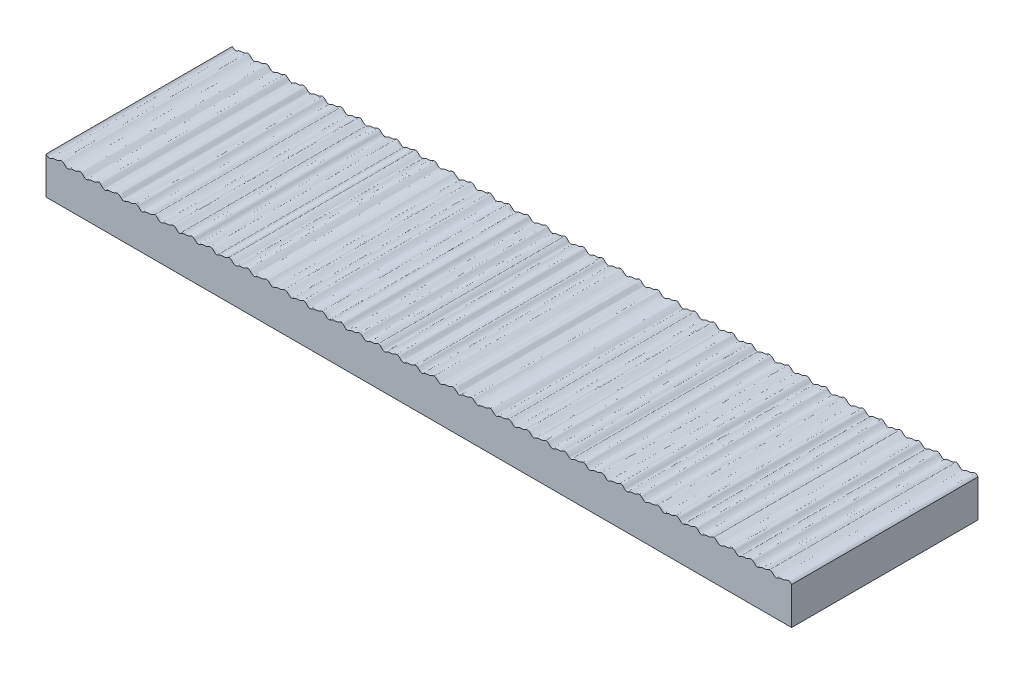
from build123d import *

# Parameters (mm, degrees)
AUFSATZ_LINEAR_AUSTRAGEN1_DEPTH = 50


with BuildPart() as part:
    # Skizze1 → Aufsatz-Linear austragen1 (new body)
    with BuildSketch(Plane.XY):
        with BuildLine():
            Line((0, 10), (0, 0))
            Line((0, 0), (200, 0))
            Line((200, 0), (200, 10))
            add(Edge.make_bspline(
                [(0, 10), (0.038871089, 9.9624255), (0.11702428, 9.886873009), (0.276737044, 9.737095424), (0.495618179, 9.574292073), (0.754441657, 9.479986587), (1.049992657, 9.511261754), (1.327344431, 9.647732145), (1.60121182, 9.808766789), (1.902075358, 9.947101731), (2.237499296, 10.009048627), (2.586757818, 9.993970597), (2.946471246, 10.009722426), (3.263298936, 10.120845427), (3.531006903, 10.268992249), (3.776360671, 10.406692069), (4.017368484, 10.500855503), (4.293691085, 10.512062256), (4.564534381, 10.393279584), (4.800469273, 10.195913237), (5.028254164, 9.971117802), (5.268757369, 9.741852772), (5.552089834, 9.524071152), (5.920599081, 9.460805432), (6.266877461, 9.61234611), (6.570328253, 9.792390203), (6.891296463, 9.946288536), (7.250351856, 10.011452379), (7.62394339, 9.990965887), (8.008625251, 10.018030827), (8.376673484, 10.174422263), (8.690787962, 10.36507936), (9.018441303, 10.517317828), (9.363236477, 10.501706612), (9.64337149, 10.3346189), (9.880145513, 10.11915348), (10.109095252, 9.891391142), (10.344924431, 9.675136757), (10.622007039, 9.503571421), (10.968628303, 9.478594675), (11.302531496, 9.630175237), (11.62068572, 9.824828569), (11.996749128, 9.984609573), (12.393610743, 10.008851228), (12.783268099, 9.987314285), (13.161026782, 10.070833664), (13.49661328, 10.245155578), (13.802756534, 10.429635366), (14.142662835, 10.536834855), (14.472635266, 10.452177992), (14.729423203, 10.260314552), (14.958198319, 10.041887758), (15.18510968, 9.818067104), (15.429495011, 9.60953776), (15.730640788, 9.472549737), (16.084248747, 9.515630957), (16.410046579, 9.696899556), (16.74774908, 9.893538576), (17.155927752, 10.014076689), (17.553067713, 9.993440973), (17.927068171, 10.006356508), (18.261848119, 10.119990196), (18.549112573, 10.278129114), (18.842465296, 10.446718051), (19.195620226, 10.546061299), (19.539019392, 10.419204885), (19.802164344, 10.192388079), (20.037064537, 9.9635673), (20.262328894, 9.746611116), (20.511601262, 9.557962321), (20.808247177, 9.471565216), (21.102847658, 9.534306739), (21.359291502, 9.667253571), (21.617045832, 9.816252525), (21.900679029, 9.945421938), (22.219126239, 10.006405946), (22.553791581, 9.996802936), (22.883121715, 10.003332903), (23.195663169, 10.091180614), (23.478068363, 10.236757212), (23.745304841, 10.393157976), (24.034272651, 10.514248601), (24.344051381, 10.503743403), (24.611045863, 10.357227987), (24.831726174, 10.165158584), (25.071246058, 9.930454513), (25.336079093, 9.673184544), (25.687032096, 9.449935604), (26.09873171, 9.521085126), (26.412296768, 9.699660856), (26.697060041, 9.859708273), (27.017604872, 9.980900347), (27.370952722, 10.00948623), (27.73813766, 9.987043257), (28.113616402, 10.053110139), (28.476265058, 10.228020595), (28.822248672, 10.452289625), (29.242208205, 10.560483904), (29.607605302, 10.367351586), (29.868946165, 10.129645547), (30.098851256, 9.901406058), (30.344722201, 9.67480196), (30.653334501, 9.480061877), (31.034864297, 9.490722074), (31.371828404, 9.675531968), (31.694469979, 9.861705889), (32.052756763, 9.993522458), (32.427494335, 10.005230593), (32.79942052, 9.990399164), (33.162357039, 10.072520288), (33.489242391, 10.241268416), (33.789859342, 10.421315157), (34.123520925, 10.535314959), (34.455474815, 10.461927375), (34.716154449, 10.272071242), (34.945125081, 10.054865901), (35.170268898, 9.832357357), (35.41192242, 9.622668881), (35.709941595, 9.47564196), (36.069404412, 9.508172221), (36.402677895, 9.69209825), (36.74529488, 9.893335316), (37.161842288, 10.015992572), (37.568598234, 9.991592755), (37.955025353, 10.009972842), (38.300756727, 10.13785313), (38.598560837, 10.307306898), (38.897179111, 10.473484133), (39.240435869, 10.534659041), (39.553847991, 10.402637659), (39.799429176, 10.195797026), (40.024293661, 9.975812646), (40.247927092, 9.760295346), (40.501491338, 9.562089987), (40.822393068, 9.462419812), (41.162490636, 9.553918035), (41.468411845, 9.732832958), (41.789407641, 9.908438311), (42.155505817, 10.007146527), (42.522720105, 9.997674758), (42.87987885, 10.000158701), (43.215424704, 10.097791717), (43.513844145, 10.257025062), (43.810232277, 10.430748729), (44.162975656, 10.546582186), (44.514544643, 10.435915535), (44.782741381, 10.210600813), (45.019571636, 9.981086348), (45.246289938, 9.760843927), (45.492142256, 9.569516453), (45.781276704, 9.474595016), (46.069307679, 9.522889165), (46.31887487, 9.64415856), (46.570713621, 9.790224661), (46.84844162, 9.926965953), (47.167688784, 10.003938775), (47.511582883, 9.99923192), (47.848444583, 9.99835257), (48.16904752, 10.079829846), (48.457283322, 10.224613704), (48.726822809, 10.383061623), (49.012528117, 10.508620252), (49.317641503, 10.509456233), (49.581857518, 10.37717567), (49.797823523, 10.197026067), (50.035322543, 9.965690671), (50.299903346, 9.707044754), (50.641543404, 9.458760107), (51.064926146, 9.505764773), (51.383368004, 9.682738036), (51.663126755, 9.84187017), (51.975955667, 9.970157985), (52.323555324, 10.010736789), (52.685713944, 9.988297998), (53.057607971, 10.035309587), (53.428813779, 10.199612309), (53.776594901, 10.425464572), (54.197154945, 10.568625599), (54.581718687, 10.388929519), (54.848223606, 10.149226694), (55.078016545, 9.922032462), (55.321943024, 9.694364324), (55.623175378, 9.490880482), (56.002405395, 9.479959539), (56.34129367, 9.65706852), (56.656563727, 9.840977742), (57.00189745, 9.981202446), (57.372255225, 10.009032536), (57.745518898, 9.987925954), (58.118377788, 10.054234062), (58.460068612, 10.223431381), (58.765567319, 10.408661135), (59.099361567, 10.532676166), (59.434536852, 10.471885152), (59.698486888, 10.287688499), (59.928809329, 10.071101948), (60.155052629, 9.846824711), (60.394978938, 9.635381313), (60.686999884, 9.481867427), (61.04228334, 9.498990436), (61.373969778, 9.674230397), (61.707101879, 9.872986595), (62.109943546, 10.00888555), (62.506940662, 9.997710842), (62.880883944, 9.999128234), (63.220203258, 10.100815565), (63.511437533, 10.25583632), (63.803203019, 10.425963249), (64.149480372, 10.545348605), (64.501336123, 10.444127777), (64.771334637, 10.221327368), (65.006885445, 9.993254753), (65.232667897, 9.775058953), (65.503344076, 9.554680283), (65.884000114, 9.44446765), (66.264440302, 9.606354531), (66.599285836, 9.812789929), (66.958851734, 9.969596686), (67.326663758, 10.010651372), (67.684591605, 9.989539475), (68.029279684, 10.031457859), (68.340485369, 10.159826707), (68.619212058, 10.319691981), (68.919557198, 10.482985277), (69.288291989, 10.537529396), (69.635951814, 10.353089588), (69.916820034, 10.07827219), (70.211248112, 9.798945292), (70.557208636, 9.486943479), (71.03219531, 9.465993417), (71.409749679, 9.706530477), (71.760997535, 9.891595694), (72.123059292, 10.00464779), (72.49735312, 9.999907774), (72.871724538, 9.995683751), (73.23345952, 10.102750608), (73.55973182, 10.282752426), (73.885605603, 10.475480738), (74.281754513, 10.54325695), (74.640158788, 10.349207633), (74.920570013, 10.074748387), (75.214913249, 9.795122222), (75.562619767, 9.484025383), (76.037923533, 9.46832622), (76.414155319, 9.709414391), (76.766154636, 9.893944989), (77.128477549, 10.005294961), (77.50271681, 9.999471765), (77.877041813, 9.996336411), (78.238277054, 10.105003127), (78.564034949, 10.285368685), (78.890457041, 10.477852405), (79.287241068, 10.542166338), (79.64413884, 10.345711497), (79.924411864, 10.070894856), (80.218542228, 9.791760605), (80.568083363, 9.480447831), (81.052787835, 9.471688932), (81.439879317, 9.725777339), (81.816627646, 9.920775845), (82.218457166, 10.017581107), (82.60948912, 9.988935845), (82.983018394, 10.017250375), (83.318090471, 10.147014102), (83.611002978, 10.314791989), (83.921534998, 10.486079123), (84.300612424, 10.537004943), (84.648113491, 10.340734792), (84.927934792, 10.071317471), (85.179302018, 9.822095099), (85.425961534, 9.61382234), (85.689835983, 9.497208174), (85.940939975, 9.491229327), (86.216662754, 9.585549981), (86.499398319, 9.749704513), (86.821552296, 9.926770029), (87.224056861, 10.015641491), (87.614758768, 9.98951945), (87.988255783, 10.018117326), (88.3227197, 10.149518207), (88.615342682, 10.317380589), (88.926470703, 10.488177114), (89.306012884, 10.535769108), (89.652095606, 10.337163387), (89.931679989, 10.067656366), (90.183139187, 9.818333432), (90.430555557, 9.610593376), (90.69534953, 9.495904626), (90.946540395, 9.492267942), (91.221658753, 9.58819184), (91.504078904, 9.752531532), (91.826757901, 9.928948846), (92.229511048, 10.015762836), (92.620096149, 9.989179736), (92.993462748, 10.019359883), (93.327348026, 10.151921362), (93.61967894, 10.31999728), (93.931420131, 10.49023876), (94.311397411, 10.534482736), (94.656059509, 10.333587209), (94.935425719, 10.063995411), (95.186978616, 9.814573357), (95.435168834, 9.607383435), (95.700877131, 9.494651791), (95.952135154, 9.493353165), (96.22664781, 9.590846955), (96.508765724, 9.755358109), (96.83198012, 9.931104199), (97.234959866, 10.015867005), (97.625451507, 9.988834609), (97.998618545, 10.020677837), (98.33210944, 10.154177683), (98.623579295, 10.323092371), (98.905630551, 10.474031258), (99.203505776, 10.524062924), (99.467871637, 10.443169682), (99.67728564, 10.301575596), (99.866865705, 10.130765074), (100.051545763, 9.949035785), (100.243107511, 9.765752409), (100.458427236, 9.596599111), (100.724498075, 9.482374151), (101.026574123, 9.502763422), (101.308226445, 9.636864299), (101.581227366, 9.797482051), (101.879174409, 9.939086115), (102.212427039, 10.007846377), (102.560915196, 9.995675011), (102.919744743, 10.005103269), (103.238977354, 10.109443757), (103.509109369, 10.256108484), (103.755301599, 10.395896655), (103.99709123, 10.496047867), (104.284603735, 10.516774391), (104.575387933, 10.390319088), (104.827713203, 10.17052581), (105.080169591, 9.919983141), (105.344284202, 9.670691058), (105.683883514, 9.463546569), (106.087196847, 9.508467312), (106.426355674, 9.709779365), (106.763433, 9.89632942), (107.134711359, 10.006897611), (107.503553121, 9.998358648), (107.856905509, 9.998771567), (108.184860943, 10.086109958), (108.47245228, 10.23345417), (108.759999624, 10.401107552), (109.09619878, 10.539988081), (109.459176706, 10.471052568), (109.743064087, 10.247765267), (109.985442945, 10.014560047), (110.218379607, 9.788544084), (110.495193531, 9.557053963), (110.890608574, 9.440468697), (111.28237732, 9.61651884), (111.627570207, 9.829754481), (112.006154983, 9.984342725), (112.387720723, 10.00849239), (112.753287622, 9.988803875), (113.09676525, 10.052778373), (113.39728466, 10.191145638), (113.665473588, 10.346293141), (113.960188574, 10.496483226), (114.316405826, 10.527421546), (114.623735107, 10.352816412), (114.867593351, 10.130525672), (115.087912047, 9.91272187), (115.299587619, 9.716680451), (115.565135971, 9.525894316), (115.929742065, 9.457619466), (116.305533345, 9.629828254), (116.665263622, 9.853031112), (117.090831447, 10.012418605), (117.540423452, 9.994409356), (117.948515973, 10.003127498), (118.291213395, 10.135577545), (118.568879091, 10.290450861), (118.810694122, 10.424050485), (119.117793054, 10.533089356), (119.489450969, 10.465839859), (119.768010227, 10.22410267), (120.014901025, 9.985352092), (120.232483911, 9.776361831), (120.431693514, 9.617328912), (120.717647158, 9.473498724), (121.107894173, 9.506379536), (121.452749435, 9.732302295), (121.83872598, 9.932428631), (122.245627049, 10.014328001), (122.627626136, 9.989589537), (122.986278017, 10.01837087), (123.300105682, 10.14023627), (123.5696776, 10.290921987), (123.819440422, 10.429925432), (124.09529767, 10.521160319), (124.382670154, 10.487091966), (124.630208611, 10.340937103), (124.840717109, 10.156014567), (125.071565472, 9.929855589), (125.329477082, 9.681414088), (125.669362464, 9.456529432), (126.083947915, 9.512584476), (126.404538689, 9.695217316), (126.699153115, 9.861728488), (127.029973685, 9.984771749), (127.391859909, 10.008810988), (127.764516886, 9.986794089), (128.142068561, 10.062958703), (128.497215634, 10.242212489), (128.837781112, 10.45778395), (129.253632074, 10.55647941), (129.623920461, 10.358576004), (129.895435234, 10.102610145), (130.152581926, 9.851243003), (130.438677745, 9.587856131), (130.858048453, 9.427713731), (131.275622481, 9.609981312), (131.62551144, 9.830154671), (132.005584455, 9.982604224), (132.378644552, 10.008599752), (132.741351368, 9.98909334), (133.087387985, 10.048545597), (133.395137382, 10.189162736), (133.673169482, 10.351896653), (133.982838714, 10.50706534), (134.357080634, 10.520057958), (134.687144607, 10.305028775), (134.965425467, 10.034623739), (135.217792362, 9.784580465), (135.472787039, 9.582462815), (135.745539122, 9.486507434), (135.996637144, 9.503642188), (136.266316014, 9.612511844), (136.546547356, 9.77787842), (136.874197557, 9.94760857), (137.278645105, 10.015787454), (137.668228855, 9.986742808), (138.040057151, 10.031672378), (138.368648362, 10.173897725), (138.65870709, 10.343522129), (138.976576025, 10.507414451), (139.359101584, 10.520554623), (139.690997849, 10.301323258), (139.969162256, 10.031009275), (140.221664778, 9.78082176), (140.477578884, 9.579458177), (140.751168689, 9.485728768), (141.002161773, 9.50511985), (141.271246405, 9.615265013), (141.551305998, 9.78068081), (141.879531099, 9.949568466), (142.284108313, 10.015678525), (142.673588811, 9.986549294), (143.04520381, 10.033163853), (143.37320172, 10.176375373), (143.66305147, 10.346132713), (143.981662955, 10.509157342), (144.36431316, 10.51875517), (144.694808032, 10.297734412), (144.972913186, 10.027339345), (145.225537302, 9.77708215), (145.48239222, 9.576475425), (145.756806473, 9.4850051), (146.007676711, 9.506637845), (146.276171061, 9.618026518), (146.556072828, 9.783480044), (146.88487681, 9.951503166), (147.289571373, 10.015550941), (147.678953177, 9.986367428), (148.050338908, 10.034695207), (148.377765838, 10.178810416), (148.667347811, 10.34889133), (148.982708401, 10.508412984), (149.354699068, 10.517987486), (149.676484654, 10.312483579), (149.944567713, 10.055562993), (150.190175334, 9.81163145), (150.439070594, 9.604111209), (150.715261326, 9.488083548), (150.986568772, 9.498245665), (151.269528116, 9.612832565), (151.556694027, 9.784506046), (151.890240448, 9.953328077), (152.295034394, 10.015422324), (152.684318641, 9.986202468), (153.055473429, 10.036237056), (153.382305634, 10.181300292), (153.671702747, 10.351501579), (153.987803761, 10.5100932), (154.359885749, 10.516240391), (154.680360093, 10.308970556), (154.948301158, 10.051889307), (155.19401451, 9.807903771), (155.443702316, 9.600926952), (155.720865511, 9.486998802), (155.992135263, 9.499688696), (156.274463283, 9.615632117), (156.561460236, 9.787295257), (156.895611076, 9.955218316), (157.300498677, 10.015250653), (157.689686566, 9.986061928), (158.060601851, 10.037800607), (158.386839548, 10.183797404), (158.676061823, 10.354110444), (158.992913235, 10.511737609), (159.365055113, 10.514445422), (159.68422301, 10.30545501), (159.952034898, 10.048214116), (160.197857213, 9.804178065), (160.44835362, 9.597763192), (160.726481237, 9.485968305), (160.99769121, 9.50117395), (161.279391443, 9.618440059), (161.566235498, 9.790080434), (161.900992762, 9.957083255), (162.305963504, 10.015059477), (162.695057208, 9.985939678), (163.065724085, 10.039387906), (163.391367859, 10.18630096), (163.680425487, 10.356718046), (163.998036875, 10.5133455), (164.370207003, 10.512603124), (164.68807393, 10.301937079), (164.955768967, 10.044537393), (165.201703662, 9.800454341), (165.453024683, 9.594620599), (165.732107923, 9.484992426), (166.00323627, 9.502700686), (166.284312764, 9.621255891), (166.57101988, 9.79286138), (166.906385301, 9.958922522), (167.311428851, 10.014849258), (167.700430615, 9.985836116), (168.070840133, 10.040998799), (168.395890813, 10.188810869), (168.684794199, 10.359324295), (169.003174731, 10.514916227), (169.375341258, 10.510714014), (169.691913414, 10.298416909), (169.959503348, 10.040859126), (170.205554003, 9.796732396), (170.45771603, 9.591500346), (170.737745773, 9.484072329), (171.008758609, 9.504256622), (171.293169778, 9.625792766), (171.586151363, 9.802118983), (171.935568906, 9.971137269), (172.358756969, 10.013899934), (172.756321068, 9.984393807), (173.12389065, 10.060020392), (173.436143856, 10.212309605), (173.711544304, 10.374270007), (174.021236175, 10.517253766), (174.384118038, 10.506240866), (174.695725307, 10.294926809), (174.963238444, 10.037171076), (175.209409584, 9.793014539), (175.462426864, 9.588401661), (175.743392619, 9.483206746), (176.014280951, 9.505864631), (176.298067729, 9.628636214), (176.590952813, 9.804888114), (176.941025113, 9.972819612), (177.364196002, 10.013474541), (177.761698956, 9.984525532), (178.128902555, 10.061879778), (178.440621083, 10.214821212), (178.715947267, 10.376943047), (179.022185465, 10.516428765), (179.374585021, 10.506052229), (179.677430406, 10.309537464), (179.934732877, 10.065562871), (180.173950956, 9.827528315), (180.41980095, 9.617173912), (180.70158766, 9.487025963), (180.992972957, 9.496924513), (181.295467937, 9.626049494), (181.601758778, 9.812200958), (181.970610667, 9.984399326), (182.41136947, 10.010457989), (182.817718259, 9.985566924), (183.180881235, 10.083292194), (183.480749569, 10.238629128), (183.742952527, 10.390438091), (184.040429437, 10.51831358), (184.383282044, 10.501650531), (184.681318004, 10.306135893), (184.938457563, 10.061867645), (185.177779538, 9.823815398), (185.424335745, 9.613896855), (185.707193748, 9.485794495), (185.998547476, 9.498441289), (186.300339615, 9.628924193), (186.606574516, 9.814967271), (186.976122599, 9.985909552), (187.416784351, 10.00985035), (187.823093304, 9.985989564), (188.185784948, 10.085344548), (188.485192985, 10.241204755), (188.747423902, 10.39291406), (189.045612107, 10.519514435), (189.38832613, 10.499683298), (189.685203935, 10.302676907), (189.942179912, 10.058188406), (190.181612686, 9.820098932), (190.428889459, 9.610638172), (190.712813103, 9.484617513), (191.004110549, 9.500000464), (191.305204621, 9.631803777), (191.611401483, 9.817728224), (191.981642762, 9.987389035), (192.422200544, 10.009233542), (192.828470283, 9.986438941), (193.190682016, 10.087414664), (193.489635495, 10.243784518), (193.751904173, 10.395384957), (194.050807421, 10.520674437), (194.393353603, 10.497672446), (194.689079916, 10.299213427), (194.945902627, 10.054506897), (195.185449967, 9.816384068), (195.433462492, 9.607397268), (195.718445177, 9.483495714), (196.009661556, 9.501601401), (196.31006444, 9.634687024), (196.616236245, 9.820485741), (196.987177615, 9.988833446), (197.427605767, 10.008615481), (197.833883935, 9.986892987), (198.195345675, 10.089664371), (198.495464418, 10.245356808), (198.750471085, 10.402186458), (199.10004084, 10.52347952), (199.462904351, 10.503078221), (199.784381242, 10.208227458), (199.927646556, 10.069940015), (200, 10)],
                knots=[0.082466751, 0.082466751, 0.082466751, 0.082466751, 0.082466751, 0.083445681, 0.084424611, 0.085403541, 0.086382471, 0.087588185, 0.0887939, 0.089999614, 0.091205329, 0.092556701, 0.093908073, 0.095259445, 0.096610817, 0.097573764, 0.098536711, 0.099499658, 0.100462605, 0.101675555, 0.102888504, 0.104101453, 0.105314403, 0.106733488, 0.108152574, 0.109481494, 0.110810414, 0.112139334, 0.113468254, 0.114952567, 0.11643688, 0.117921194, 0.119405507, 0.120574457, 0.121743407, 0.122967338, 0.12419127, 0.125415201, 0.126639133, 0.127809689, 0.128980244, 0.130494587, 0.132008929, 0.133523271, 0.135037613, 0.136456883, 0.137876153, 0.139295424, 0.140714694, 0.141887501, 0.143060308, 0.144268352, 0.145476396, 0.146684441, 0.147892485, 0.149097727, 0.150302969, 0.151878987, 0.153455004, 0.155031021, 0.156607039, 0.157844087, 0.159081135, 0.160318183, 0.161555231, 0.162973466, 0.164391702, 0.165577596, 0.16676349, 0.167949384, 0.169135278, 0.170217765, 0.171300252, 0.172382739, 0.173465226, 0.174724922, 0.175984619, 0.177244316, 0.178504013, 0.179678296, 0.180852579, 0.182026862, 0.183201145, 0.184303597, 0.185406048, 0.186508499, 0.187610951, 0.189356732, 0.191102513, 0.192336625, 0.193570737, 0.194804849, 0.19603896, 0.197467959, 0.198896957, 0.200325956, 0.201754954, 0.203476343, 0.205197731, 0.206419563, 0.207641395, 0.208863227, 0.210085059, 0.211510804, 0.212936549, 0.214354871, 0.215773193, 0.217191515, 0.218609838, 0.21999001, 0.221370183, 0.222750356, 0.224130528, 0.225320436, 0.226510344, 0.227709448, 0.228908551, 0.230107655, 0.231306759, 0.232532255, 0.233757751, 0.235363097, 0.236968443, 0.238573789, 0.240179135, 0.241477536, 0.242775936, 0.244074337, 0.245372738, 0.246607865, 0.247842993, 0.249020428, 0.250197864, 0.251375299, 0.252552735, 0.25382035, 0.255087966, 0.25650269, 0.257917415, 0.25933214, 0.260746865, 0.262018708, 0.263290552, 0.264562395, 0.265834238, 0.267248761, 0.268663284, 0.269861704, 0.271060125, 0.272258545, 0.273456966, 0.274494185, 0.275531404, 0.276568623, 0.277605842, 0.278899179, 0.280192516, 0.281485852, 0.282779189, 0.28396524, 0.285151291, 0.286337343, 0.287523394, 0.288580186, 0.289636979, 0.290693771, 0.291750564, 0.29356612, 0.295381676, 0.296600149, 0.297818622, 0.299037094, 0.300255567, 0.301664905, 0.303074243, 0.304483581, 0.305892918, 0.307684926, 0.309476933, 0.310696231, 0.311915529, 0.313134826, 0.314354124, 0.315781275, 0.317208427, 0.31859372, 0.319979013, 0.321364307, 0.3227496, 0.324175091, 0.325600581, 0.327026072, 0.328451562, 0.329623226, 0.330794889, 0.332001952, 0.333209015, 0.334416079, 0.335623142, 0.336827306, 0.33803147, 0.339603285, 0.3411751, 0.342746916, 0.344318731, 0.345560431, 0.34680213, 0.34804383, 0.349285529, 0.350701076, 0.352116622, 0.353306103, 0.354495585, 0.355685066, 0.356874547, 0.358524532, 0.360174518, 0.361564693, 0.362954868, 0.364345043, 0.365735218, 0.366952298, 0.368169379, 0.369386459, 0.370603539, 0.372081075, 0.373558611, 0.375036147, 0.376513683, 0.378379138, 0.380244594, 0.381651334, 0.383058074, 0.384464814, 0.385871554, 0.387278294, 0.388685035, 0.390091775, 0.391498515, 0.392976449, 0.394454382, 0.395932316, 0.397410249, 0.399275941, 0.401141633, 0.402548115, 0.403954598, 0.40536108, 0.406767563, 0.408174046, 0.409580528, 0.410987011, 0.412393493, 0.41387183, 0.415350166, 0.416828502, 0.418306838, 0.420172776, 0.422038714, 0.423572482, 0.42510625, 0.426640018, 0.428173786, 0.42945272, 0.430731655, 0.432010589, 0.433289524, 0.434768267, 0.436247011, 0.437725754, 0.439204498, 0.440137595, 0.441070691, 0.442003788, 0.442936885, 0.444470349, 0.446003813, 0.447537276, 0.44907074, 0.450349445, 0.451628151, 0.452906857, 0.454185562, 0.455664718, 0.457143873, 0.458623028, 0.460102183, 0.461035413, 0.461968643, 0.462901872, 0.463835102, 0.465368256, 0.466901409, 0.468434563, 0.469967717, 0.471246189, 0.472524662, 0.473803134, 0.475081606, 0.476561177, 0.478040748, 0.47952032, 0.480999891, 0.481933258, 0.482866625, 0.483799992, 0.484733359, 0.486266197, 0.487799036, 0.489331874, 0.490864712, 0.492142947, 0.493421182, 0.494699417, 0.495977652, 0.496918885, 0.497860119, 0.498801352, 0.499742585, 0.500766591, 0.501790598, 0.502814604, 0.50383861, 0.505040591, 0.506242572, 0.507444553, 0.508646534, 0.509994457, 0.51134238, 0.512690303, 0.514038226, 0.515013011, 0.515987796, 0.516962581, 0.517937366, 0.519283519, 0.520629672, 0.521975825, 0.523321979, 0.524829556, 0.526337133, 0.527779299, 0.529221465, 0.530663631, 0.532105797, 0.533320358, 0.534534919, 0.53574948, 0.536964041, 0.538397947, 0.539831854, 0.541061512, 0.542291169, 0.543520827, 0.544750485, 0.546459834, 0.548169183, 0.549609522, 0.551049862, 0.552490201, 0.55393054, 0.555106023, 0.556281506, 0.557456988, 0.558632471, 0.560047115, 0.561461759, 0.56255364, 0.563645521, 0.564737402, 0.565829283, 0.567412779, 0.568996276, 0.570686609, 0.572376942, 0.574067274, 0.575757607, 0.576800672, 0.577843736, 0.5788868, 0.579929865, 0.581611071, 0.583292276, 0.584249553, 0.58520683, 0.586164106, 0.587121383, 0.588974284, 0.590827184, 0.592266948, 0.593706713, 0.595146477, 0.596586241, 0.597664201, 0.59874216, 0.59982012, 0.60089808, 0.601954666, 0.603011252, 0.604067838, 0.605124424, 0.606828211, 0.608531999, 0.609812338, 0.611092678, 0.612373017, 0.613653356, 0.615094803, 0.61653625, 0.617977697, 0.619419144, 0.621046194, 0.622673244, 0.624030259, 0.625387275, 0.62674429, 0.628101305, 0.629909685, 0.631718065, 0.63312783, 0.634537596, 0.635947361, 0.637357126, 0.638579358, 0.639801591, 0.641023823, 0.642246055, 0.643729064, 0.645212073, 0.646695082, 0.64817809, 0.649112717, 0.650047344, 0.650981971, 0.651916599, 0.653446745, 0.654976892, 0.656507038, 0.658037185, 0.659313387, 0.660589588, 0.66186579, 0.663141991, 0.664625439, 0.666108886, 0.667592334, 0.669075781, 0.670010585, 0.670945388, 0.671880191, 0.672814994, 0.674344787, 0.67587458, 0.677404372, 0.678934165, 0.680210098, 0.681486032, 0.682761965, 0.684037898, 0.685521786, 0.687005673, 0.68848956, 0.689973447, 0.690908431, 0.691843414, 0.692778397, 0.693713381, 0.695242816, 0.696772252, 0.698301687, 0.699831123, 0.701106785, 0.702382448, 0.703658111, 0.704933773, 0.706348813, 0.707763853, 0.709178893, 0.710593932, 0.711598201, 0.712602469, 0.713606738, 0.714611006, 0.716140082, 0.717669157, 0.719198233, 0.720727308, 0.722002698, 0.723278088, 0.724553477, 0.725828867, 0.727244325, 0.728659783, 0.730075241, 0.731490699, 0.732495187, 0.733499674, 0.734504162, 0.73550865, 0.737037363, 0.738566076, 0.740094789, 0.741623502, 0.742898617, 0.744173731, 0.745448846, 0.74672396, 0.748139837, 0.749555713, 0.75097159, 0.752387467, 0.753392177, 0.754396886, 0.755401596, 0.756406305, 0.757934653, 0.759463002, 0.76099135, 0.762519698, 0.763794535, 0.765069373, 0.76634421, 0.767619048, 0.769035343, 0.770451639, 0.771867935, 0.77328423, 0.774289164, 0.775294098, 0.776299032, 0.777303966, 0.778831947, 0.780359928, 0.78188791, 0.783415891, 0.784690449, 0.785965008, 0.787239567, 0.788514125, 0.78993084, 0.791347554, 0.792764269, 0.794180984, 0.795186144, 0.796191304, 0.797196465, 0.798201625, 0.799792129, 0.801382633, 0.802973137, 0.804563641, 0.805775207, 0.806986773, 0.808198338, 0.809409904, 0.810827037, 0.81224417, 0.813661303, 0.815078436, 0.816083826, 0.817089215, 0.818094604, 0.819099993, 0.820690107, 0.82228022, 0.823870334, 0.825460448, 0.826671755, 0.827883063, 0.82909437, 0.830305678, 0.831653816, 0.833001955, 0.834350094, 0.835698233, 0.836773077, 0.837847921, 0.838922765, 0.839997609, 0.841650183, 0.843302757, 0.84495533, 0.846607904, 0.84775629, 0.848904676, 0.850053062, 0.851201447, 0.852549984, 0.853898522, 0.855247059, 0.856595596, 0.857670695, 0.858745795, 0.859820894, 0.860895993, 0.862548156, 0.864200318, 0.86585248, 0.867504642, 0.868652795, 0.869800948, 0.870949101, 0.872097253, 0.873446189, 0.874795124, 0.876144059, 0.877492994, 0.878568349, 0.879643705, 0.88071906, 0.881794416, 0.883446166, 0.885097917, 0.886749668, 0.888401419, 0.889549337, 0.890697256, 0.891845174, 0.892993093, 0.894342425, 0.895691757, 0.897041089, 0.898390421, 0.899466034, 0.900541646, 0.901617258, 0.902692871, 0.90434421, 0.90599555, 0.907646889, 0.909298229, 0.910445912, 0.911593595, 0.912741279, 0.913888962, 0.915711112, 0.917533262, 0.917533262, 0.917533262, 0.917533262, 0.917533262], degree=4))
        make_face()
    extrude(amount=AUFSATZ_LINEAR_AUSTRAGEN1_DEPTH)


solid = part.part
